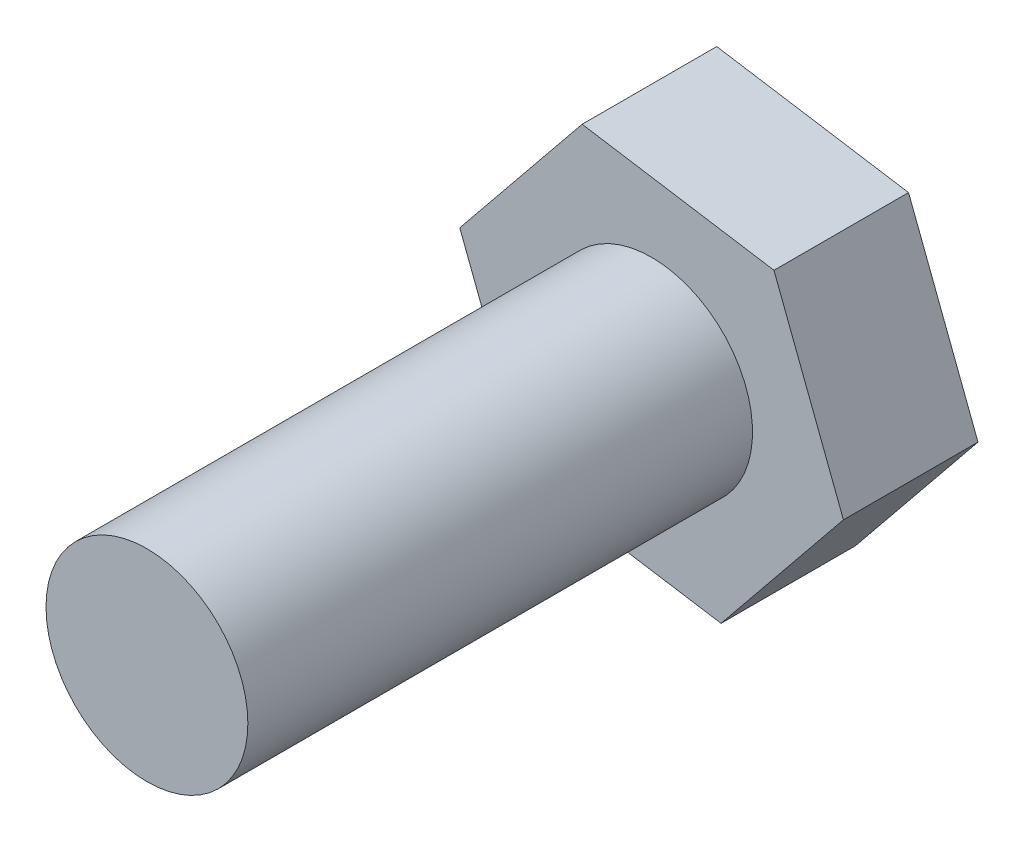
from build123d import *

# Parameters (mm, degrees)
SKETCH_1_R      = 0.3
EXTRUDE_1_DEPTH = 1.5
EXTRUDE_2_DEPTH = 0.4


with BuildPart() as part:
    # 草图1 → 凸台-拉伸1 (new body)
    with BuildSketch(Plane.XY):
        Circle(SKETCH_1_R)
    extrude(amount=EXTRUDE_1_DEPTH)

    # 草图2 → 凸台-拉伸2 (add)
    with BuildSketch(Plane(origin=(0, 0, 0), x_dir=(-1, 0, 0), z_dir=(0, 0, -1))):
        Polygon((0.363723427, -0.448373284), (0.570164368, 0.090807086), (0.206440941, 0.53918037), (-0.363723427, 0.448373284), (-0.570164368, -0.090807086), (-0.206440941, -0.53918037), align=None)
    extrude(amount=EXTRUDE_2_DEPTH)


solid = part.part
